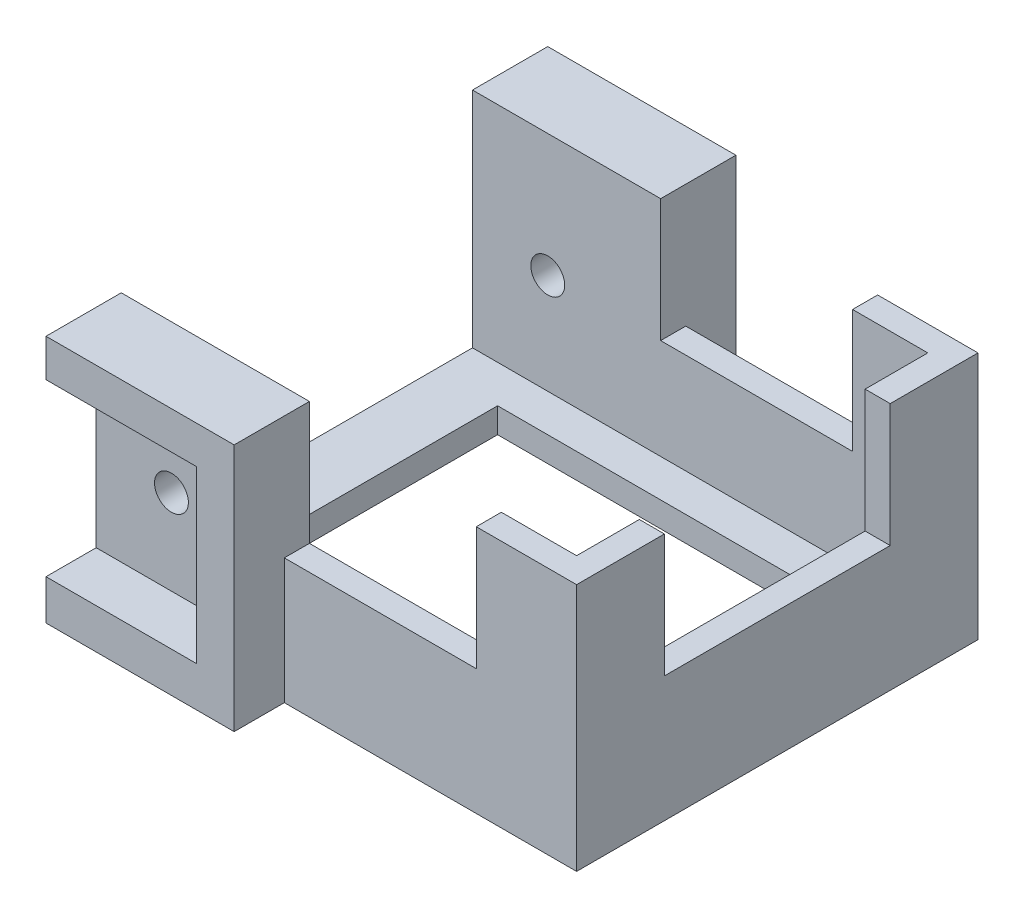
from build123d import *

# Parameters (mm, degrees)
SKETCH_1_W           = 38.3
SKETCH_1_H           = 32
EXTRUDE_1_DEPTH      = 2
EXTRUDE_2_DEPTH      = 75
SKETCH_9_R           = 1.35
CUT_EXTRUDE_5_DEPTH  = 33
SKETCH_10_W          = 15.3
SKETCH_10_H          = 52
CUT_EXTRUDE_6_DEPTH  = 33
SKETCH_11_W          = 28.3
SKETCH_11_H          = 22
CUT_EXTRUDE_7_DEPTH  = 78
SKETCH_13_W          = 18
SKETCH_13_H          = 57
CUT_EXTRUDE_8_DEPTH  = 39.3
SKETCH_14_W          = 5
SKETCH_14_H          = 2
CUT_EXTRUDE_9_DEPTH  = 33
EXTRUDE_3_DEPTH      = 4
SKETCH_17_W          = 38.3
SKETCH_17_H          = 32
CUT_EXTRUDE_10_DEPTH = 57.2


with BuildPart() as part:
    # Эскиз1 → Бобышка-Вытянуть1 (new body)
    with BuildSketch(Plane(origin=(0, 0, 0), x_dir=(1, 0, 0), z_dir=(0, 1, 0))):
        Rectangle(SKETCH_1_W, SKETCH_1_H)
    extrude(amount=EXTRUDE_1_DEPTH)

    # Эскиз2 → Бобышка-Вытянуть2 (add)
    with BuildSketch(Plane(origin=(0, 2, 0), x_dir=(1, 0, 0), z_dir=(0, 1, 0))):
        Polygon((-19.15, 16), (19.15, 16), (19.15, -16), (-19.15, -16), (-19.15, -14), (17.15, -14), (17.15, 14), (-19.15, 14), align=None)
    extrude(amount=EXTRUDE_2_DEPTH)

    # Эскиз9 → Вырез-Вытянуть5 (cut, through all)
    with BuildSketch(Plane.XY.offset(16)):
        with Locations((-13.15, 69)):
            Circle(SKETCH_9_R)
        with Locations((-13.15, 10)):
            Circle(SKETCH_9_R)
    extrude(amount=-CUT_EXTRUDE_5_DEPTH, mode=Mode.SUBTRACT)

    # Эскиз10 → Вырез-Вытянуть6 (cut, through all)
    with BuildSketch(Plane.XY.offset(16)):
        with Locations((3.5, 36)):
            Rectangle(SKETCH_10_W, SKETCH_10_H)
    extrude(amount=-CUT_EXTRUDE_6_DEPTH, mode=Mode.SUBTRACT)

    # Эскиз11 → Вырез-Вытянуть7 (cut, through all)
    with BuildSketch(Plane.XZ):
        Rectangle(SKETCH_11_W, SKETCH_11_H)
    extrude(amount=-CUT_EXTRUDE_7_DEPTH, mode=Mode.SUBTRACT)

    # Эскиз13 → Вырез-Вытянуть8 (cut, through all)
    with BuildSketch(Plane(origin=(19.15, 0, 0), x_dir=(0, 0, -1), z_dir=(1, 0, 0))):
        with Locations((0, 38.5)):
            Rectangle(SKETCH_13_W, SKETCH_13_H)
    extrude(amount=-CUT_EXTRUDE_8_DEPTH, mode=Mode.SUBTRACT)

    # Эскиз14 → Вырез-Вытянуть9 (cut, through all)
    with BuildSketch(Plane(origin=(0, 0, -16), x_dir=(-1, 0, 0), z_dir=(0, 0, -1))):
        with Locations((-11.65, 71)):
            Rectangle(SKETCH_14_W, SKETCH_14_H)
        with Locations((1.65, 71)):
            Rectangle(SKETCH_14_W, SKETCH_14_H)
    extrude(amount=-CUT_EXTRUDE_9_DEPTH, mode=Mode.SUBTRACT)

    # Эскиз16 → Бобышка-Вытянуть3 (add)
    with BuildSketch(Plane.XY.offset(16)):
        Polygon((-19.15, 0), (-4.15, 0), (-4.15, 19.8), (-19.15, 19.8), (-19.15, 16.8), (-7.15, 16.8), (-7.15, 3.2), (-19.15, 3.2), align=None)
    extrude_3 = extrude(amount=EXTRUDE_3_DEPTH)

    # Зеркальное отражение1: Бобышка-Вытянуть3 across plane
    add(extrude_3.mirror(Plane.XY))

    # Эскиз17 → Вырез-Вытянуть10 (cut)
    with BuildSketch(Plane(origin=(0, 77, 0), x_dir=(1, 0, 0), z_dir=(0, 1, 0))):
        Rectangle(SKETCH_17_W, SKETCH_17_H)
    extrude(amount=-CUT_EXTRUDE_10_DEPTH, mode=Mode.SUBTRACT)


solid = part.part
